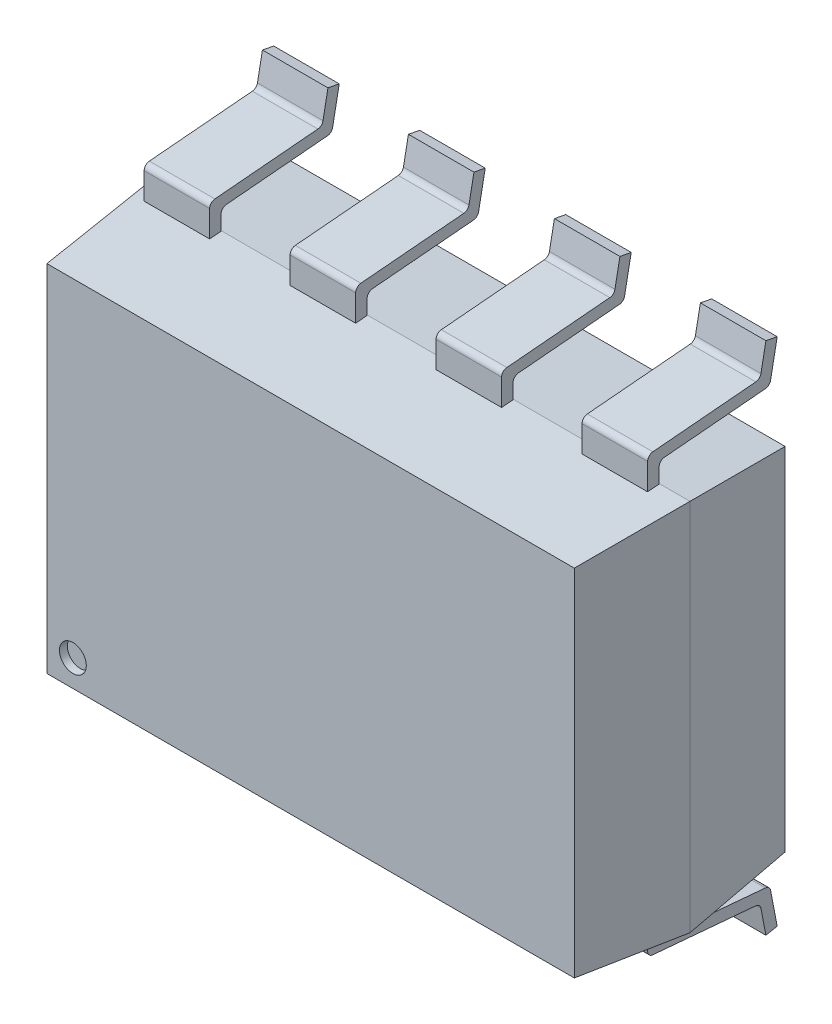
from build123d import *

# Parameters (mm, degrees)
SKETCH1_W            = 9.5
SKETCH1_H            = 6.5
BOSS_EXTRUDE1_DEPTH  = 1.85
BOSS_EXTRUDE1_TAPER  = 5
SKETCH2_W            = 9.5
SKETCH2_H            = 6.5
BOSS_EXTRUDE2_DEPTH  = 1.85
BOSS_EXTRUDE2_TAPER  = 6
SKETCH3_R            = 0.23364323
CUT_EXTRUDE1_DEPTH   = 0.127
CUT_EXTRUDE1_TAPER   = 5
EXTRUDE_THIN1_DEPTH  = 0.57
LPATTERN4_COUNT      = 4
LPATTERN4_PITCH      = 2.54
FILLET1_R            = 0.1
FILLET2_R            = 0.1
FILLET3_R            = 0.1
FILLET4_R            = 0.1
MIRROR3_COPY_1_DEPTH = 0.57
MIRROR3_COPY_2_DEPTH = 0.57
MIRROR3_COPY_3_DEPTH = 0.57
FILLET1_OF_MIRROR3_R = 0.1
FILLET2_OF_MIRROR3_R = 0.1
FILLET3_OF_MIRROR3_R = 0.1
FILLET4_OF_MIRROR3_R = 0.1


with BuildPart() as part:
    # Sketch1 → Boss-Extrude1 (new body)
    with BuildSketch(Plane.XY):
        with Locations((4.75, 3.25)):
            Rectangle(SKETCH1_W, SKETCH1_H)
    extrude(amount=BOSS_EXTRUDE1_DEPTH, taper=BOSS_EXTRUDE1_TAPER)

    # Sketch3 → Cut-Extrude1 (cut)
    with BuildSketch(Plane.XY.offset(1.85)):
        with Locations((0.613779647, 0.622126205)):
            Circle(SKETCH3_R)
    extrude(amount=-CUT_EXTRUDE1_DEPTH, taper=CUT_EXTRUDE1_TAPER, mode=Mode.SUBTRACT)


with BuildPart() as body_2:
    # Sketch2 → Boss-Extrude2 (new body)
    with BuildSketch(Plane(origin=(0, 0, 0), x_dir=(-1, 0, 0), z_dir=(0, 0, -1))):
        with Locations((-4.75, 3.25)):
            Rectangle(SKETCH2_W, SKETCH2_H)
    extrude(amount=BOSS_EXTRUDE2_DEPTH, taper=BOSS_EXTRUDE2_TAPER)


with BuildPart() as body_3:
    # Sketch4 → Extrude-Thin1 (new body, symmetric)
    with BuildSketch(Plane(origin=(0.78, 0, 0), x_dir=(0, 0, -1), z_dir=(1, 0, 0))):
        Polygon((-0.206806083, 0.220421263), (-0.206806083, -0.531590318), (1.750873937, -0.703783231), (1.851792217, -1.229631136), (2.048207783, -1.191935975), (1.918827654, -0.51778388), (-0.006806083, -0.348409682), (-0.006806083, 0.220421263), align=None)
    extrude_thin1 = extrude(amount=EXTRUDE_THIN1_DEPTH, both=True)

    # Fillet1
    fillet1_edges = [body_3.edges().sort_by_distance(p)[0] for p in [
        (0.78, -0.703783231, -1.750873937),
        (0.78, -0.531590318, 0.206806083),
        (0.78, -0.348409682, 0.006806083),
        (0.78, -0.51778388, -1.918827654),
    ]]
    fillet(fillet1_edges, radius=FILLET1_R)


with BuildPart() as lpattern4_1:
    # LPattern4: pattern copy
    add(extrude_thin1.moved(Location(Vector(1, 0, 0) * (1 * LPATTERN4_PITCH))))

    # Fillet2
    fillet2_edges = [lpattern4_1.edges().sort_by_distance(p)[0] for p in [
        (3.32, -0.703783231, -1.750873937),
        (3.32, -0.531590318, 0.206806083),
        (3.32, -0.348409682, 0.006806083),
        (3.32, -0.51778388, -1.918827654),
    ]]
    fillet(fillet2_edges, radius=FILLET2_R)


with BuildPart() as lpattern4_2:
    # LPattern4: pattern copy
    add(extrude_thin1.moved(Location(Vector(1, 0, 0) * (2 * LPATTERN4_PITCH))))

    # Fillet3
    fillet3_edges = [lpattern4_2.edges().sort_by_distance(p)[0] for p in [
        (5.86, -0.703783231, -1.750873937),
        (5.86, -0.531590318, 0.206806083),
        (5.86, -0.348409682, 0.006806083),
        (5.86, -0.51778388, -1.918827654),
    ]]
    fillet(fillet3_edges, radius=FILLET3_R)


with BuildPart() as lpattern4_3:
    # LPattern4: pattern copy
    add(extrude_thin1.moved(Location(Vector(1, 0, 0) * (3 * LPATTERN4_PITCH))))

    # Fillet4
    fillet4_edges = [lpattern4_3.edges().sort_by_distance(p)[0] for p in [
        (8.4, -0.703783231, -1.750873937),
        (8.4, -0.531590318, 0.206806083),
        (8.4, -0.348409682, 0.006806083),
        (8.4, -0.51778388, -1.918827654),
    ]]
    fillet(fillet4_edges, radius=FILLET4_R)


with BuildPart() as part_1:
    add(part.part)

    # Mirror3: Extrude-Thin1 across plane
    add(extrude_thin1.mirror(Plane.ZX.offset(3.25)))

    # Mirror3 copy 1 sketch → Mirror3 copy 1 (add, symmetric)
    with BuildSketch(Plane(origin=(3.32, 6.5, 0), x_dir=(0, 0, -1), z_dir=(1, 0, 0))):
        Polygon((-0.206806083, -0.220421263), (-0.206806083, 0.531590318), (1.750873937, 0.703783231), (1.851792217, 1.229631136), (2.048207783, 1.191935975), (1.918827654, 0.51778388), (-0.006806083, 0.348409682), (-0.006806083, -0.220421263), align=None)
    extrude(amount=MIRROR3_COPY_1_DEPTH, both=True)

    # Mirror3 copy 2 sketch → Mirror3 copy 2 (add, symmetric)
    with BuildSketch(Plane(origin=(5.86, 6.5, 0), x_dir=(0, 0, -1), z_dir=(1, 0, 0))):
        Polygon((-0.206806083, -0.220421263), (-0.206806083, 0.531590318), (1.750873937, 0.703783231), (1.851792217, 1.229631136), (2.048207783, 1.191935975), (1.918827654, 0.51778388), (-0.006806083, 0.348409682), (-0.006806083, -0.220421263), align=None)
    extrude(amount=MIRROR3_COPY_2_DEPTH, both=True)

    # Mirror3 copy 3 sketch → Mirror3 copy 3 (add, symmetric)
    with BuildSketch(Plane(origin=(8.4, 6.5, 0), x_dir=(0, 0, -1), z_dir=(1, 0, 0))):
        Polygon((-0.206806083, -0.220421263), (-0.206806083, 0.531590318), (1.750873937, 0.703783231), (1.851792217, 1.229631136), (2.048207783, 1.191935975), (1.918827654, 0.51778388), (-0.006806083, 0.348409682), (-0.006806083, -0.220421263), align=None)
    extrude(amount=MIRROR3_COPY_3_DEPTH, both=True)

    # Fillet1 of Mirror3
    fillet1_of_mirror3_edges = [part_1.edges().sort_by_distance(p)[0] for p in [
        (0.78, 7.203783231, -1.750873937),
        (0.78, 7.031590318, 0.206806083),
        (0.78, 6.848409682, 0.006806083),
        (0.78, 7.01778388, -1.918827654),
    ]]
    fillet(fillet1_of_mirror3_edges, radius=FILLET1_OF_MIRROR3_R)

    # Fillet2 of Mirror3
    fillet2_of_mirror3_edges = [part_1.edges().sort_by_distance(p)[0] for p in [
        (3.32, 7.203783231, -1.750873937),
        (3.32, 7.031590318, 0.206806083),
        (3.32, 6.848409682, 0.006806083),
        (3.32, 7.01778388, -1.918827654),
    ]]
    fillet(fillet2_of_mirror3_edges, radius=FILLET2_OF_MIRROR3_R)

    # Fillet3 of Mirror3
    fillet3_of_mirror3_edges = [part_1.edges().sort_by_distance(p)[0] for p in [
        (5.86, 7.203783231, -1.750873937),
        (5.86, 7.031590318, 0.206806083),
        (5.86, 6.848409682, 0.006806083),
        (5.86, 7.01778388, -1.918827654),
    ]]
    fillet(fillet3_of_mirror3_edges, radius=FILLET3_OF_MIRROR3_R)

    # Fillet4 of Mirror3
    fillet4_of_mirror3_edges = [part_1.edges().sort_by_distance(p)[0] for p in [
        (8.4, 7.203783231, -1.750873937),
        (8.4, 7.031590318, 0.206806083),
        (8.4, 6.848409682, 0.006806083),
        (8.4, 7.01778388, -1.918827654),
    ]]
    fillet(fillet4_of_mirror3_edges, radius=FILLET4_OF_MIRROR3_R)


solid = Compound([body_2.part, body_3.part, lpattern4_1.part, lpattern4_2.part, lpattern4_3.part, part_1.part])
